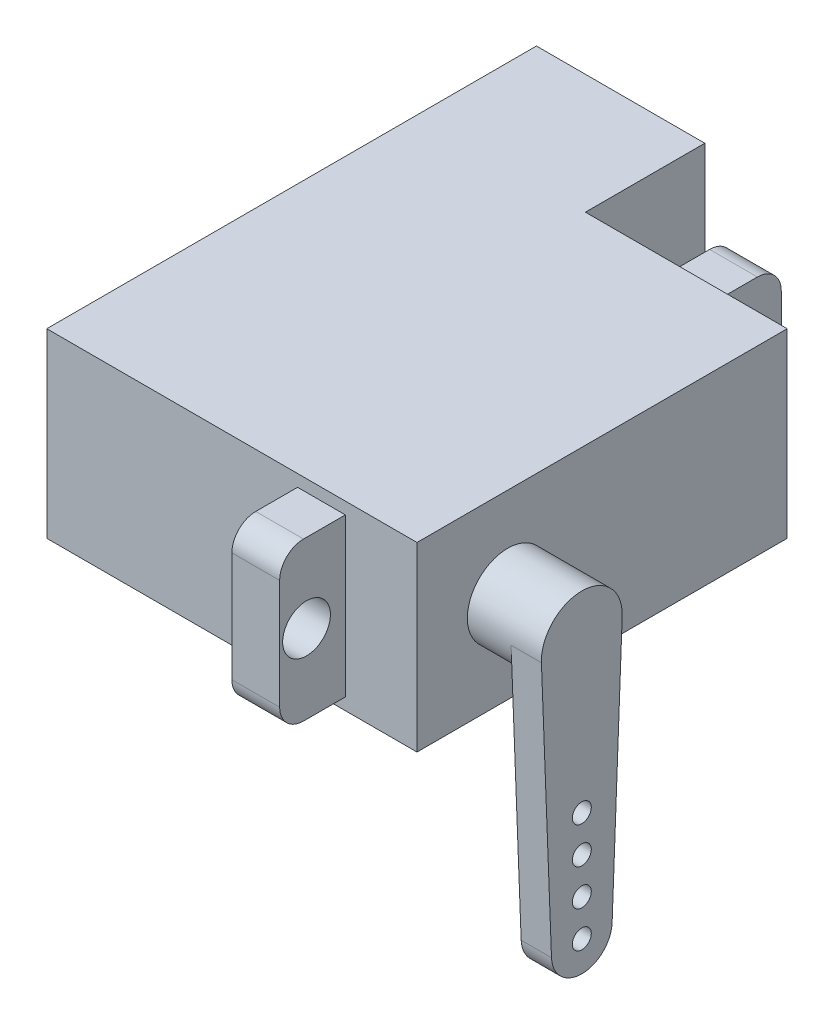
from build123d import *

# Parameters (mm, degrees)
SKETCH1_W                          = 31
SKETCH1_H                          = 15.2
BOSS_EXTRUDE1_DEPTH                = 31
BOSS_EXTRUDE2_START                = 21
BOSS_EXTRUDE2_DEPTH                = 4
F_4_0MM_DOWEL_HOLE1_D              = 4
F_4_0MM_DOWEL_HOLE1_DEPTH          = 10.668
F_4_0MM_DOWEL_HOLE1_TIP            = 1.201721238
SKETCH6_R                          = 3.38413067
BOSS_EXTRUDE3_DEPTH                = 6.2
BOSS_EXTRUDE4_DEPTH                = 2.54
F_1_16_0_0625_DIAMETER_HOLE1_D     = 1.5875
F_1_16_0_0625_DIAMETER_HOLE1_DEPTH = 2.54
SKETCH12_W                         = 14.1
SKETCH12_H                         = 15.2
BOSS_EXTRUDE5_DEPTH                = 10


with BuildPart() as part:
    # Sketch1 → Boss-Extrude1 (new body)
    with BuildSketch(Plane(origin=(0, 0, 0), x_dir=(0, 0, -1), z_dir=(1, 0, 0))):
        Rectangle(SKETCH1_W, SKETCH1_H)
    extrude(amount=BOSS_EXTRUDE1_DEPTH)

    # Sketch2 → Boss-Extrude2 (add)
    with BuildSketch(Plane(origin=(0, 0, 0), x_dir=(0, 0, -1), z_dir=(1, 0, 0)).offset(BOSS_EXTRUDE2_START)):
        with BuildLine():
            Line((-15.5, 6.6), (-19, 6.6))
            ThreePointArc((-19, 6.6), (-20.414213562, 6.014213562), (-21, 4.6))
            Line((-21, 4.6), (-21, -4.6))
            ThreePointArc((-21, -4.6), (-20.414213562, -6.014213562), (-19, -6.6))
            Line((-19, -6.6), (-15.5, -6.6))
            Line((-15.5, -6.6), (-15.5, 6.6))
        make_face()
        with BuildLine():
            Line((15.5, -6.6), (19, -6.6))
            ThreePointArc((19, -6.6), (20.414213562, -6.014213562), (21, -4.6))
            Line((21, -4.6), (21, 4.6))
            ThreePointArc((21, 4.6), (20.414213562, 6.014213562), (19, 6.6))
            Line((19, 6.6), (15.5, 6.6))
            Line((15.5, 6.6), (15.5, -6.6))
        make_face()
    extrude(amount=BOSS_EXTRUDE2_DEPTH)

    # Ø4.0mm Dowel Hole1
    with Locations(Plane(origin=(25, 0, 0), x_dir=(0, 0, -1), z_dir=(1, 0, 0))):
        with Locations((-18.75, 0), (18.75, 0)):
            Hole(F_4_0MM_DOWEL_HOLE1_D / 2, depth=F_4_0MM_DOWEL_HOLE1_DEPTH)
            with Locations((0, 0, -(F_4_0MM_DOWEL_HOLE1_DEPTH + F_4_0MM_DOWEL_HOLE1_TIP / 2))):  # 118° drill point
                Cone(0, F_4_0MM_DOWEL_HOLE1_D / 2, F_4_0MM_DOWEL_HOLE1_TIP, mode=Mode.SUBTRACT)

    # Sketch6 → Boss-Extrude3 (add)
    with BuildSketch(Plane(origin=(31, 0, 0), x_dir=(0, 0, -1), z_dir=(1, 0, 0))):
        with Locations((-7.9, 0)):
            Circle(SKETCH6_R)
    extrude(amount=BOSS_EXTRUDE3_DEPTH)

    # Sketch7 → Boss-Extrude4 (add)
    with BuildSketch(Plane(origin=(37.2, 0, 0), x_dir=(0, 0, -1), z_dir=(1, 0, 0))):
        with BuildLine():
            Line((-4.518397081, -0.130774972), (-5.361897234, -21.942154729))
            ThreePointArc((-5.361897234, -21.942154729), (-7.9, -24.384), (-10.438102766, -21.942154729))
            Line((-10.438102766, -21.942154729), (-11.281602919, -0.130774972))
            ThreePointArc((-11.281602919, -0.130774972), (-7.9, 3.38413067), (-4.518397081, -0.130774972))
        make_face()
    extrude(amount=-BOSS_EXTRUDE4_DEPTH)

    # 1_16 _0.0625_ Diameter Hole1
    with Locations(Plane(origin=(37.2, 0, 0), x_dir=(0, 0, -1), z_dir=(1, 0, 0))):
        with Locations((-7.9, -12.7), (-7.9, -15.748), (-7.9, -18.796), (-7.9, -21.844)):
            Hole(F_1_16_0_0625_DIAMETER_HOLE1_D / 2, depth=F_1_16_0_0625_DIAMETER_HOLE1_DEPTH)

    # Sketch12 → Boss-Extrude5 (add)
    with BuildSketch(Plane(origin=(0, 0, -15.5), x_dir=(-1, 0, 0), z_dir=(0, 0, -1))):
        with Locations((-7.05, 0)):
            Rectangle(SKETCH12_W, SKETCH12_H)
    extrude(amount=BOSS_EXTRUDE5_DEPTH)


solid = part.part
